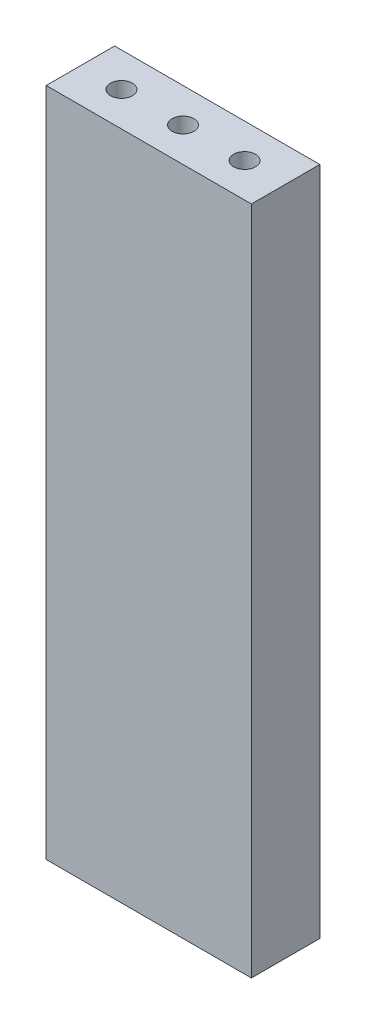
from build123d import *

# Parameters (mm, degrees)
SKETCH1_W             = 15
SKETCH1_H             = 5
BOSS_EXTRUDE1_DEPTH   = 49
M2_TAPPED_HOLE1_D     = 1.6
M2_TAPPED_HOLE1_DEPTH = 11.2
M2_TAPPED_HOLE1_TIP   = 0.480688495
M2_TAPPED_HOLE2_D     = 1.6
M2_TAPPED_HOLE2_DEPTH = 11.2
M2_TAPPED_HOLE2_TIP   = 0.480688495


with BuildPart() as part:
    # Sketch1 → Boss-Extrude1 (new body)
    with BuildSketch(Plane(origin=(0, 0, 0), x_dir=(1, 0, 0), z_dir=(0, 1, 0))):
        Rectangle(SKETCH1_W, SKETCH1_H)
    extrude(amount=-BOSS_EXTRUDE1_DEPTH)

    # M2 Tapped Hole1
    with Locations(Plane.XZ.offset(49)):
        with Locations((-4.5, 0), (4.5, 0), (0, 0)):
            Hole(M2_TAPPED_HOLE1_D / 2, depth=M2_TAPPED_HOLE1_DEPTH)
            with Locations((0, 0, -(M2_TAPPED_HOLE1_DEPTH + M2_TAPPED_HOLE1_TIP / 2))):  # 118° drill point
                Cone(0, M2_TAPPED_HOLE1_D / 2, M2_TAPPED_HOLE1_TIP, mode=Mode.SUBTRACT)

    # M2 Tapped Hole2
    with Locations(Plane(origin=(0, 0, 0), x_dir=(-1, 0, 0), z_dir=(0, 1, 0))):
        with Locations((4.5, 0), (0, 0), (-4.5, 0)):
            Hole(M2_TAPPED_HOLE2_D / 2, depth=M2_TAPPED_HOLE2_DEPTH)
            with Locations((0, 0, -(M2_TAPPED_HOLE2_DEPTH + M2_TAPPED_HOLE2_TIP / 2))):  # 118° drill point
                Cone(0, M2_TAPPED_HOLE2_D / 2, M2_TAPPED_HOLE2_TIP, mode=Mode.SUBTRACT)


solid = part.part
